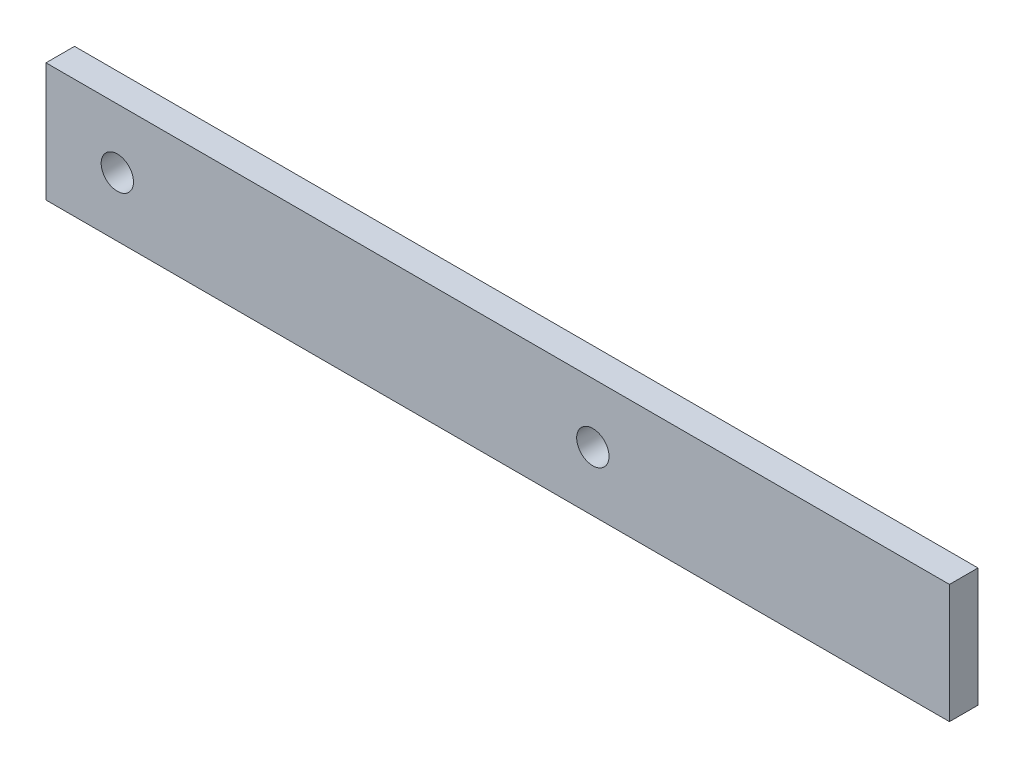
from build123d import *

# Parameters (mm, degrees)
SKETCH1_W             = 190
SKETCH1_H             = 25
SKETCH1_R             = 3.4
BASE_EXTRUDE_DEPTH    = 6
M8_TAPPED_HOLE1_D     = 6.8
M8_TAPPED_HOLE1_DEPTH = 22.25
M8_TAPPED_HOLE1_TIP   = 2.042926105


with BuildPart() as part:
    # Sketch1 → Base-Extrude (new body)
    with BuildSketch(Plane.XY):
        with Locations((-20, 0)):
            Rectangle(SKETCH1_W, SKETCH1_H)
        Circle(SKETCH1_R, mode=Mode.SUBTRACT)
        with Locations((-100, 0)):
            Circle(SKETCH1_R, mode=Mode.SUBTRACT)
    extrude(amount=BASE_EXTRUDE_DEPTH)

    # M8 Tapped Hole1
    with Locations(Plane(origin=(-100, 0, 6), x_dir=(1, 0, 0), z_dir=(0, 0, 1))):
        with Locations((0, 0), (100, 0)):
            Hole(M8_TAPPED_HOLE1_D / 2, depth=M8_TAPPED_HOLE1_DEPTH)
            with Locations((0, 0, -(M8_TAPPED_HOLE1_DEPTH + M8_TAPPED_HOLE1_TIP / 2))):  # 118° drill point
                Cone(0, M8_TAPPED_HOLE1_D / 2, M8_TAPPED_HOLE1_TIP, mode=Mode.SUBTRACT)


solid = part.part
